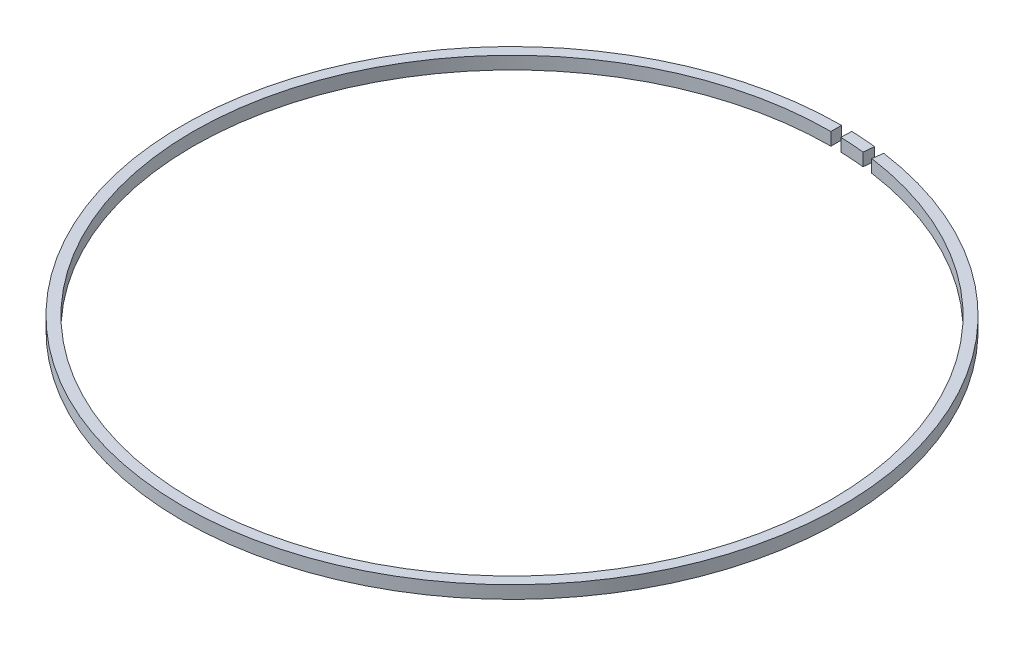
from build123d import *

# Parameters (mm, degrees)
SKETCH1_R               = 77.5
SKETCH1_R_2             = 75
BOSS_EXTRUDE1_DEPTH     = 3
CUT_EXTRUDE1_DEPTH      = 1
CUT_EXTRUDE1_DEPTH_BACK = 4


with BuildPart() as part:
    # Sketch1 → Boss-Extrude1 (new body)
    with BuildSketch(Plane(origin=(0, 0, 0), x_dir=(1, 0, 0), z_dir=(0, 1, 0))):
        Circle(SKETCH1_R)
        Circle(SKETCH1_R_2, mode=Mode.SUBTRACT)
    extrude(amount=BOSS_EXTRUDE1_DEPTH)

    # Sketch2 → Cut-Extrude1 (cut, two sides)
    with BuildSketch(Plane(origin=(0, 3, 0), x_dir=(1, 0, 0), z_dir=(0, 1, 0))) as cut_extrude1_sk:
        with BuildLine():
            Line((0, 75), (0, 77.5))
            ThreePointArc((0, 77.5), (1.214872553, 77.490477381), (2.429446556, 77.461911863))
            Line((2.429446556, 77.461911863), (2.351077312, 74.963140512))
            ThreePointArc((2.351077312, 74.963140512), (1.175683115, 74.990784562), (0, 75))
        make_face()
        with BuildLine():
            Line((7.961891365, 74.576191146), (8.227287744, 77.062064185))
            ThreePointArc((8.227287744, 77.062064185), (9.438939304, 76.923056572), (10.648253025, 76.764996629))
            Line((10.648253025, 76.764996629), (10.304755556, 74.28870717))
            ThreePointArc((10.304755556, 74.28870717), (9.134454673, 74.441668027), (7.961891365, 74.576191146))
        make_face()
    extrude(amount=CUT_EXTRUDE1_DEPTH, mode=Mode.SUBTRACT)
    extrude(cut_extrude1_sk.sketch, amount=-CUT_EXTRUDE1_DEPTH_BACK, mode=Mode.SUBTRACT)


solid = part.part
